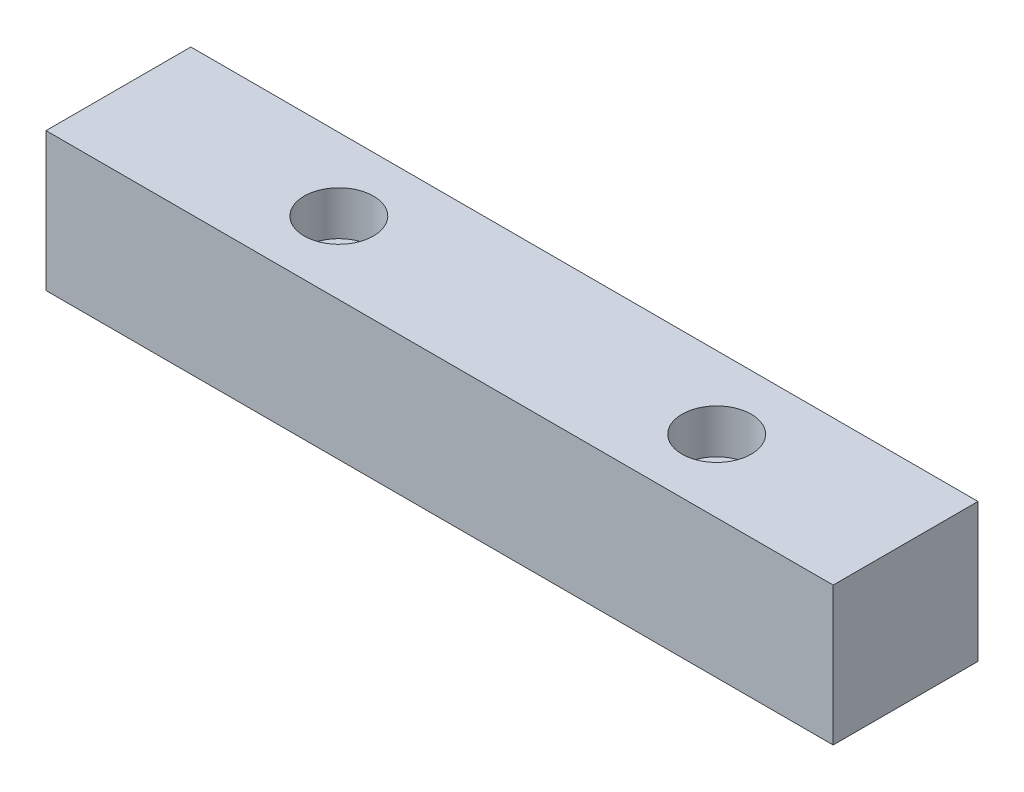
from build123d import *

# Parameters (mm, degrees)
SKETCH_1_W                = 23
SKETCH_1_H                = 22
EXTRUDE_1_DEPTH           = 125
HOLE_WIZARD_1_D           = 6.5
HOLE_WIZARD_1_CBORE_D     = 11
HOLE_WIZARD_1_CBORE_DEPTH = 7
PATTERN_LINEAR_2_COUNT    = 2
PATTERN_LINEAR_2_PITCH    = 60


with BuildPart() as part:
    # 草图1 → 凸台-拉伸1 (new body)
    with BuildSketch(Plane(origin=(0, 0, 0), x_dir=(0, 0, -1), z_dir=(1, 0, 0))):
        Rectangle(SKETCH_1_W, SKETCH_1_H)
    extrude(amount=EXTRUDE_1_DEPTH)

    # 打孔尺寸(%根据)内六角圆柱头螺钉的类型1 (through all)
    with Locations(Plane(origin=(0, 11, 0), x_dir=(1, 0, 0), z_dir=(0, 1, 0))):
        with Locations((35, 0)):
            hole_wizard_1 = CounterBoreHole(HOLE_WIZARD_1_D / 2, HOLE_WIZARD_1_CBORE_D / 2, HOLE_WIZARD_1_CBORE_DEPTH)

    # 阵列(线性)2: 打孔尺寸(%根据)内六角圆柱头螺钉的类型1 ×2
    with Locations(*[(i * PATTERN_LINEAR_2_PITCH, 0, 0) for i in range(1, PATTERN_LINEAR_2_COUNT)]):
        add(hole_wizard_1, mode=Mode.SUBTRACT)


solid = part.part
